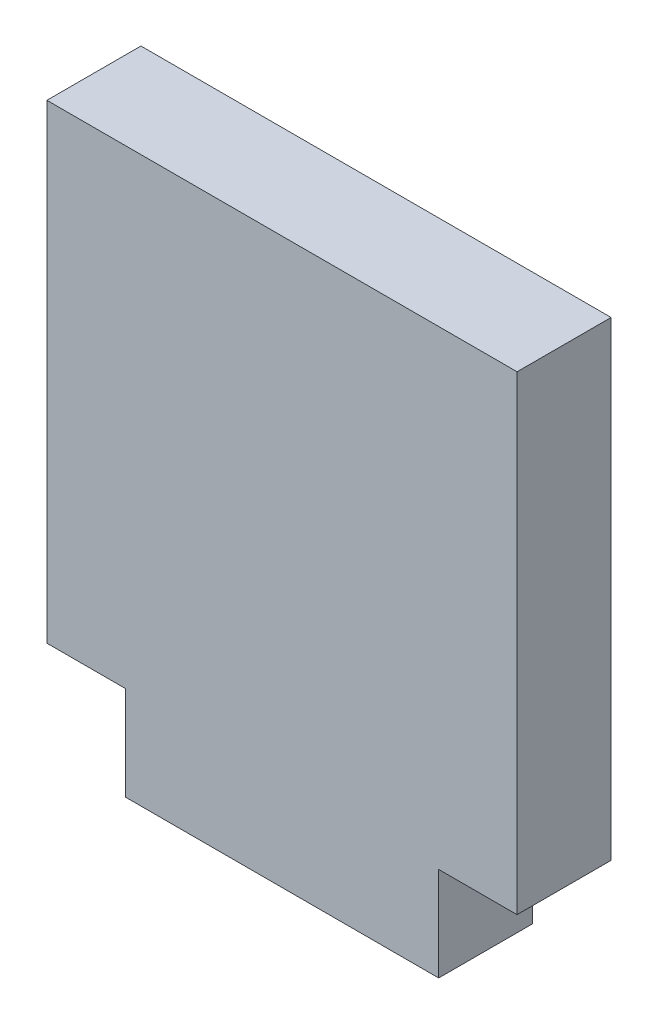
from build123d import *

# Parameters (mm, degrees)
SKETCH1_W           = 15
SKETCH1_H           = 15
SKETCH1_W_2         = 10
SKETCH1_H_2         = 3
BOSS_EXTRUDE1_DEPTH = 3


with BuildPart() as part:
    # Sketch1 → Boss-Extrude1 (new body)
    with BuildSketch(Plane.XY):
        with Locations((0, 7.5)):
            Rectangle(SKETCH1_W, SKETCH1_H)
        with Locations((0, -1.5)):
            Rectangle(SKETCH1_W_2, SKETCH1_H_2)
    extrude(amount=BOSS_EXTRUDE1_DEPTH)


solid = part.part
